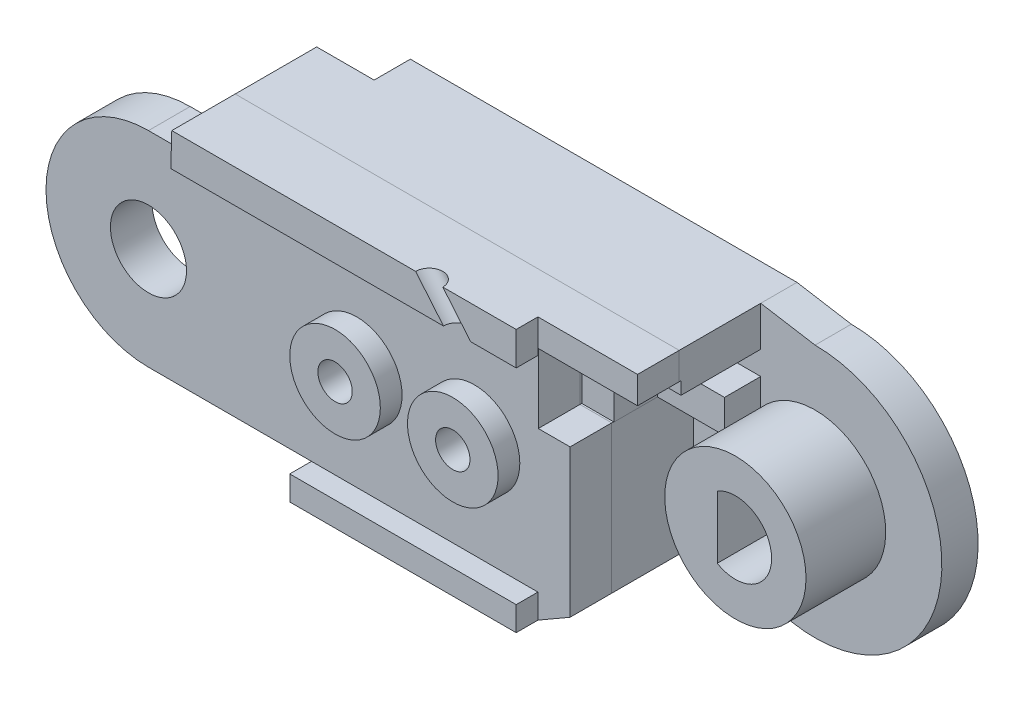
from build123d import *

# Parameters (mm, degrees)
BOSS_EXTRUDE1_DEPTH  = 2
BOSS_EXTRUDE6_DEPTH  = 4.5
CUT_EXTRUDE6_DEPTH   = 4.5
BOSS_EXTRUDE14_DEPTH = 2.3
SKETCH32_R           = 2.1
CUT_EXTRUDE7_DEPTH   = 2.3
SKETCH33_W           = 12.5
SKETCH33_H           = 1.343145751
BOSS_EXTRUDE15_DEPTH = 1.2
SKETCH35_W           = 5.479645997
SKETCH35_H           = 3.827993755
CUT_EXTRUDE8_DEPTH   = 2.4
SKETCH36_W           = 3.7
SKETCH36_H           = 1.827993755
CUT_EXTRUDE9_DEPTH   = 2.4
SKETCH37_R           = 3.9
BOSS_EXTRUDE16_DEPTH = 4.4
CUT_EXTRUDE10_DEPTH  = 7.4
SKETCH43_R           = 2.5
BOSS_EXTRUDE17_DEPTH = 1.2
SKETCH44_R           = 0.95
CUT_EXTRUDE11_DEPTH  = 11
SKETCH45_R           = 2
CUT_EXTRUDE12_DEPTH  = 4.5
SKETCH52_R           = 0.75
CUT_EXTRUDE13_DEPTH  = 10


with BuildPart() as part:
    # Sketch3 → Boss-Extrude1 (new body)
    with BuildSketch(Plane.XY):
        with BuildLine():
            Line((8, 0), (9, -2.5))
            Line((9, -2.5), (9, -7))
            Line((9, -7), (21.5, -7))
            Line((21.5, -7), (25.050252532, -4.949747468))
            ThreePointArc((25.050252532, -4.949747468), (36.467156728, -2.678784027), (30, 7))
            Line((30, 7), (27, 7.5))
            Line((27, 7.5), (5.656854249, 7.5))
            Line((5.656854249, 7.5), (5.656854249, 5.656854249))
            ThreePointArc((5.656854249, 5.656854249), (7.39103626, 3.061467459), (8, 0))
        make_face()
    extrude(amount=BOSS_EXTRUDE1_DEPTH)

    # Sketch22 → Boss-Extrude6 (add)
    with BuildSketch(Plane.XY.offset(2)):
        with BuildLine():
            Line((5.656854249, 5.656854249), (2.486790148, 5.656854249))
            Line((2.486790148, 5.656854249), (2.486790148, 7.5))
            Line((2.486790148, 7.5), (5.656854249, 7.5))
            Line((5.656854249, 7.5), (21.5, 7.5))
            Line((21.5, 7.5), (27, 7.5))
            Line((27, 7.5), (27, 2.172006245))
            Line((27, 2.172006245), (23.275126266, 2.172006245))
            Line((23.275126266, 2.172006245), (23.275126266, -5.974873734))
            Line((23.275126266, -5.974873734), (21.5, -7))
            Line((21.5, -7), (9, -7))
            Line((9, -7), (9, -2.5))
            Line((9, -2.5), (8, 0))
            ThreePointArc((8, 0), (7.39103626, 3.061467459), (5.656854249, 5.656854249))
        make_face()
    extrude(amount=BOSS_EXTRUDE6_DEPTH)

    # Sketch26 → Cut-Extrude6 (cut)
    with BuildSketch(Plane.XY.offset(2)):
        Polygon((18.098080448, 5.3), (2.530052458, 5.3), (2.530052458, 4), (18.098080448, 4), (27, 4), (27, 5.3), align=None)
    extrude(amount=CUT_EXTRUDE6_DEPTH, mode=Mode.SUBTRACT)


with BuildPart() as body_2:
    # Sketch31 → Boss-Extrude14 (new body)
    with BuildSketch(Plane.XY.offset(6.5)):
        with BuildLine():
            Line((2.432688066, 5.656854249), (0, 5.656854249))
            ThreePointArc((0, 5.656854249), (-5.656854249, 0), (0, -5.656854249))
            Line((0, -5.656854249), (9, -5.656854249))
            Line((9, -5.656854249), (9, -7))
            Line((9, -7), (21.5, -7))
            Line((21.5, -7), (23.275126266, -5.974873734))
            Line((23.275126266, -5.974873734), (23.275126266, 2.172006245))
            Line((23.275126266, 2.172006245), (27, 2.172006245))
            Line((27, 2.172006245), (27, 7.5))
            Line((27, 7.5), (2.486790148, 7.5))
            Line((2.486790148, 7.5), (2.432688066, 5.656854249))
        make_face()
    extrude(amount=BOSS_EXTRUDE14_DEPTH)

    # Sketch32 → Cut-Extrude7 (cut)
    with BuildSketch(Plane.XY.offset(8.8)):
        Circle(SKETCH32_R)
    extrude(amount=-CUT_EXTRUDE7_DEPTH, mode=Mode.SUBTRACT)

    # Sketch33 → Boss-Extrude15 (add)
    with BuildSketch(Plane.XY.offset(8.8)):
        with Locations((15.25, -6.328427125)):
            Rectangle(SKETCH33_W, SKETCH33_H)
        Polygon((2.486790148, 7.5), (21.5, 7.5), (21.5, 5.656854249), (2.432688066, 5.656854249), align=None)
    extrude(amount=BOSS_EXTRUDE15_DEPTH)


with BuildPart() as cut_extrude8_tool:
    # Sketch35 → Cut-Extrude8 (new body)
    with BuildSketch(Plane.XY.offset(8.8)):
        with Locations((24.260177002, 4.086003123)):
            Rectangle(SKETCH35_W, SKETCH35_H)
    extrude(amount=-CUT_EXTRUDE8_DEPTH)


with BuildPart() as part_1:
    add(part.part)

    # Cut-Extrude8: cut by cut_extrude8_tool
    add(cut_extrude8_tool.part, mode=Mode.SUBTRACT)

    # Sketch36 → Cut-Extrude9 (cut)
    with BuildSketch(Plane.XY.offset(6.4)):
        with Locations((25.15, 3.086003123)):
            Rectangle(SKETCH36_W, SKETCH36_H)
    extrude(amount=-CUT_EXTRUDE9_DEPTH, mode=Mode.SUBTRACT)

    # Sketch37 → Boss-Extrude16 (add)
    with BuildSketch(Plane.XY.offset(2)):
        with Locations((30, 0)):
            Circle(SKETCH37_R)
    extrude(amount=BOSS_EXTRUDE16_DEPTH)

    # Sketch39 → Cut-Extrude10 (cut, through all)
    with BuildSketch(Plane.XY.offset(6.4)):
        with BuildLine():
            Line((29, 1.732050808), (29, -1.732050808))
            ThreePointArc((29, -1.732050808), (32, 0), (29, 1.732050808))
        make_face()
    extrude(amount=-CUT_EXTRUDE10_DEPTH, mode=Mode.SUBTRACT)


with BuildPart() as body_2_1:
    add(body_2.part)

    # Cut-Extrude8: cut by cut_extrude8_tool
    add(cut_extrude8_tool.part, mode=Mode.SUBTRACT)

    # Sketch43 → Boss-Extrude17 (add)
    with BuildSketch(Plane.XY.offset(8.8)):
        with Locations((11.5, 0)):
            Circle(SKETCH43_R)
        with Locations((18, 0)):
            Circle(SKETCH43_R)
    extrude(amount=BOSS_EXTRUDE17_DEPTH)


with BuildPart() as cut_extrude11_tool:
    # Sketch44 → Cut-Extrude11 (new body, through all)
    with BuildSketch(Plane.XY.offset(10)):
        with Locations((11.5, 0)):
            Circle(SKETCH44_R)
        with Locations((18, 0)):
            Circle(SKETCH44_R)
    extrude(amount=-CUT_EXTRUDE11_DEPTH)


with BuildPart() as part_2:
    add(part_1.part)

    # Cut-Extrude11: cut by cut_extrude11_tool
    add(cut_extrude11_tool.part, mode=Mode.SUBTRACT)

    # Sketch45 → Cut-Extrude12 (cut)
    with BuildSketch(Plane(origin=(0, 0, 0), x_dir=(-1, 0, 0), z_dir=(0, 0, -1))):
        with Locations((-11.5, 0)):
            Circle(SKETCH45_R)
        with Locations((-18, 0)):
            Circle(SKETCH45_R)
    extrude(amount=-CUT_EXTRUDE12_DEPTH, mode=Mode.SUBTRACT)


with BuildPart() as body_2_2:
    add(body_2_1.part)

    # Cut-Extrude11: cut by cut_extrude11_tool
    add(cut_extrude11_tool.part, mode=Mode.SUBTRACT)

    # Sketch52 → Cut-Extrude13 (cut, along a direction that is not the sketch's normal)
    with BuildSketch(Plane.XZ.offset(-5.656854249)):
        with Locations((18.235476819, 10)):
            Circle(SKETCH52_R)
    extrude(amount=-CUT_EXTRUDE13_DEPTH, dir=(0.640410196, -0.76803306, 0), mode=Mode.SUBTRACT)


solid = Compound([part_2.part, body_2_2.part])
